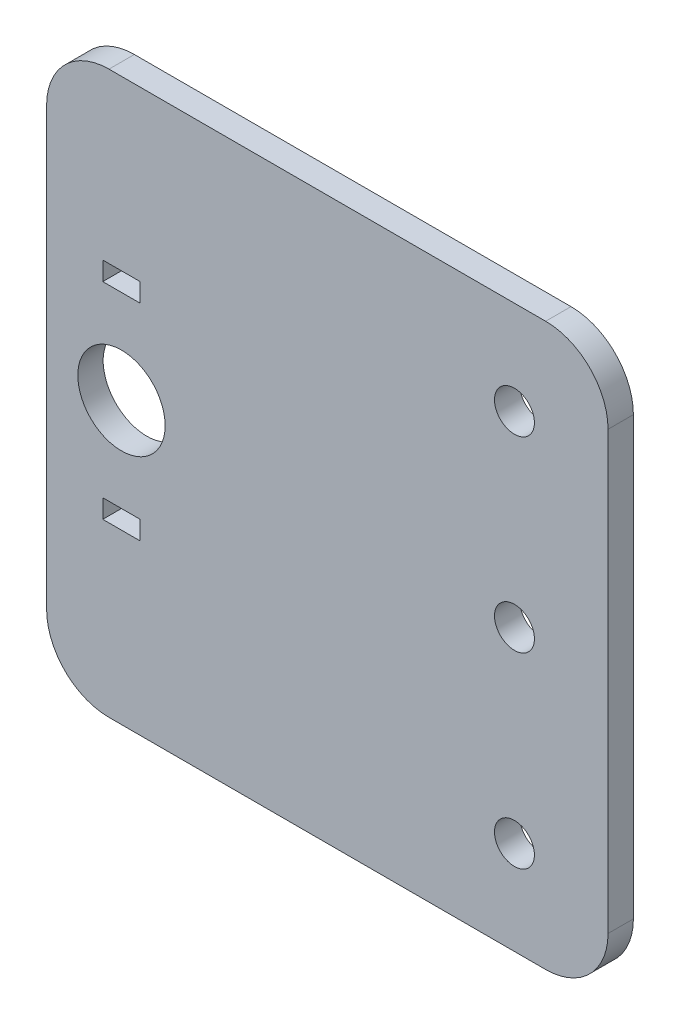
from build123d import *

# Parameters (mm, degrees)
SKETCH1_W           = 45
SKETCH1_H           = 45
SKETCH1_R           = 3.5
BOSS_EXTRUDE1_DEPTH = 2.032
FILLET2_R           = 5
SKETCH4_R           = 1.6
CUT_EXTRUDE3_DEPTH  = 3.032
SKETCH5_W           = 3
SKETCH5_H           = 1.5
CUT_EXTRUDE5_DEPTH  = 3.032


with BuildPart() as part:
    # Sketch1 → Boss-Extrude1 (new body)
    with BuildSketch(Plane.XY):
        with Locations((16.5, 0)):
            Rectangle(SKETCH1_W, SKETCH1_H)
        Circle(SKETCH1_R, mode=Mode.SUBTRACT)
    extrude(amount=BOSS_EXTRUDE1_DEPTH)

    # Fillet2
    fillet2_edges = [part.edges().sort_by_distance(p)[0] for p in [
        (39, -22.5, 1.016),
        (-6, -22.5, 1.016),
        (-6, 22.5, 1.016),
        (39, 22.5, 1.016),
    ]]
    fillet(fillet2_edges, radius=FILLET2_R)

    # Sketch4 → Cut-Extrude3 (cut, through all)
    with BuildSketch(Plane(origin=(0, 0, 0), x_dir=(-1, 0, 0), z_dir=(0, 0, -1))):
        with Locations((-31.5, 15)):
            Circle(SKETCH4_R)
        with Locations((-31.5, 0)):
            Circle(SKETCH4_R)
        with Locations((-31.5, -15)):
            Circle(SKETCH4_R)
    extrude(amount=-CUT_EXTRUDE3_DEPTH, mode=Mode.SUBTRACT)

    # Sketch5 → Cut-Extrude5 (cut, through all)
    with BuildSketch(Plane(origin=(0, 0, 0), x_dir=(-1, 0, 0), z_dir=(0, 0, -1))):
        with Locations((0, 8.25)):
            Rectangle(SKETCH5_W, SKETCH5_H)
        with Locations((0, -8.25)):
            Rectangle(SKETCH5_W, SKETCH5_H)
    extrude(amount=-CUT_EXTRUDE5_DEPTH, mode=Mode.SUBTRACT)


solid = part.part
